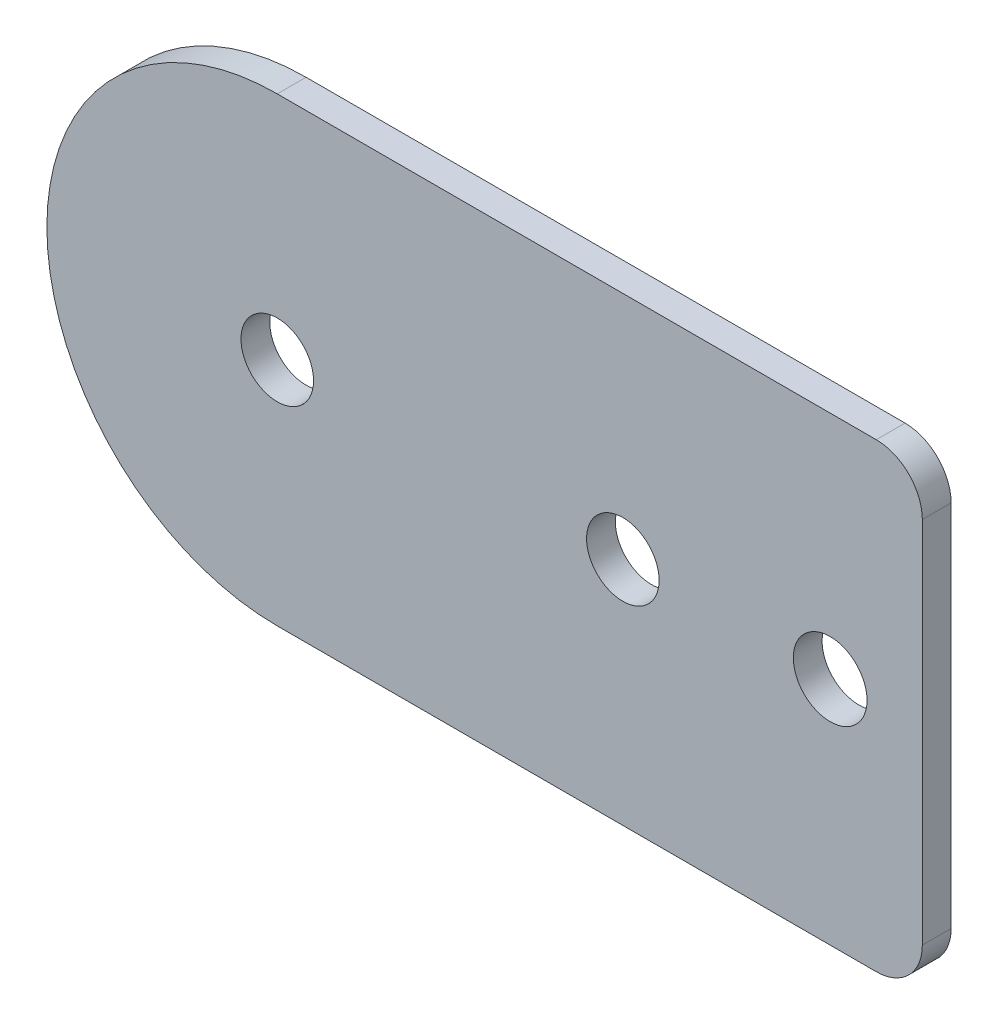
from build123d import *

# Parameters (mm, degrees)
SKETCH1_R           = 2
SKETCH1_R_2         = 2.032
BOSS_EXTRUDE1_DEPTH = 1.5875
FILLET1_R           = 2.54


with BuildPart() as part:
    # Sketch1 → Boss-Extrude1 (new body)
    with BuildSketch(Plane.XY):
        with BuildLine():
            Line((0, -12.7), (35.56, -12.7))
            Line((35.56, -12.7), (35.56, 12.7))
            Line((35.56, 12.7), (0, 12.7))
            ThreePointArc((0, 12.7), (-12.7, 0), (0, -12.7))
        make_face()
        Circle(SKETCH1_R, mode=Mode.SUBTRACT)
        with Locations((19.05, 0)):
            Circle(SKETCH1_R, mode=Mode.SUBTRACT)
        with Locations((30.48, 0)):
            Circle(SKETCH1_R_2, mode=Mode.SUBTRACT)
    extrude(amount=BOSS_EXTRUDE1_DEPTH)

    # Fillet1
    fillet1_edges = [part.edges().sort_by_distance(p)[0] for p in [
        (35.56, 12.7, 0.79375),
        (35.56, -12.7, 0.79375),
    ]]
    fillet(fillet1_edges, radius=FILLET1_R)


solid = part.part
